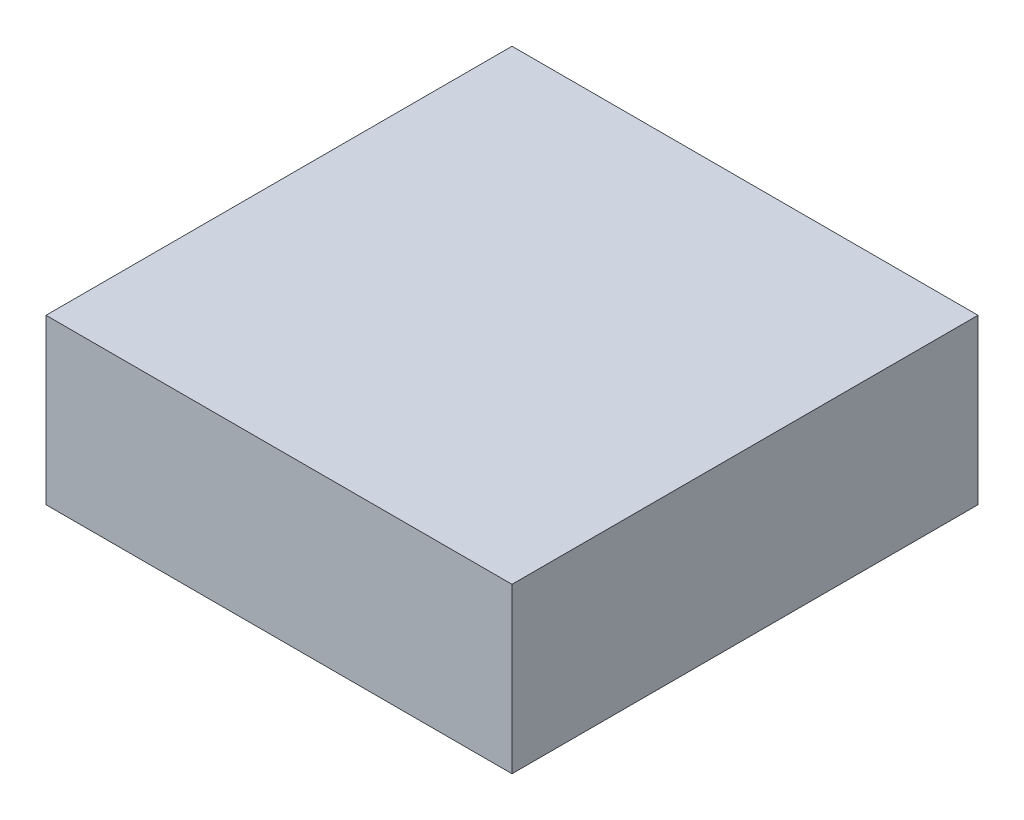
from build123d import *

# Parameters (mm, degrees)
SKETCH2_W           = 28.4
SKETCH2_H           = 28.4
BOSS_EXTRUDE1_DEPTH = 10


with BuildPart() as part:
    # Sketch2 → Boss-Extrude1 (new body)
    with BuildSketch(Plane(origin=(0, 0, 0), x_dir=(1, 0, 0), z_dir=(0, 1, 0))):
        Rectangle(SKETCH2_W, SKETCH2_H)
    extrude(amount=BOSS_EXTRUDE1_DEPTH)


solid = part.part
